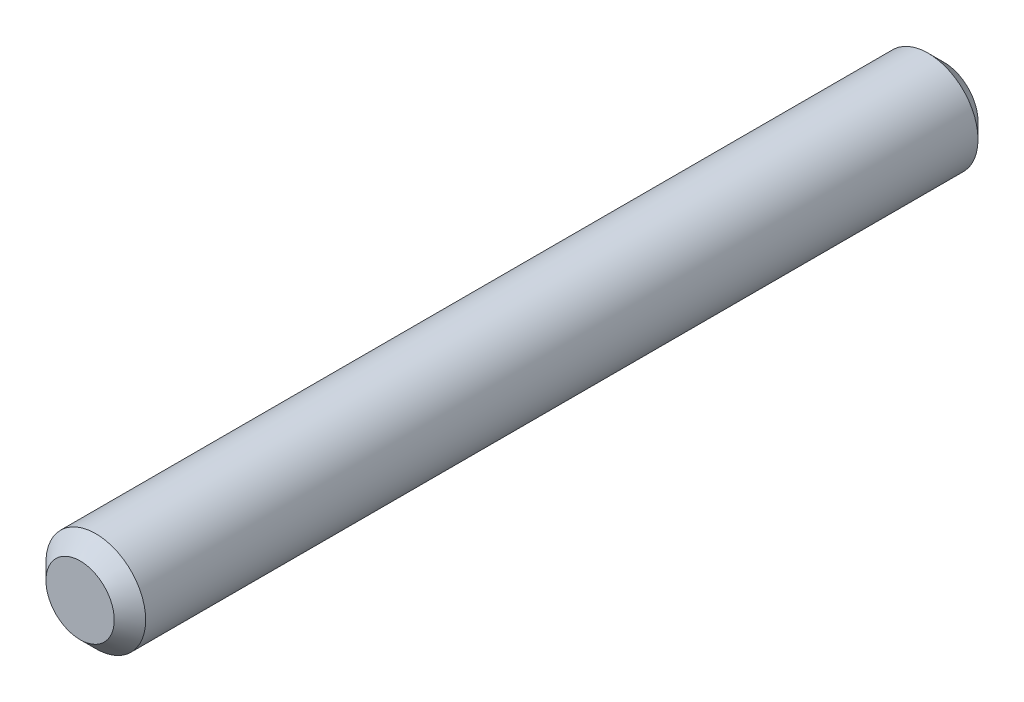
from build123d import *

# Parameters (mm, degrees)
SKETCH1_R           = 3.175
BOSS_EXTRUDE1_DEPTH = 55
CHAMFER1_SIZE       = 1


with BuildPart() as part:
    # Sketch1 → Boss-Extrude1 (new body)
    with BuildSketch(Plane.XY):
        Circle(SKETCH1_R)
    extrude(amount=-BOSS_EXTRUDE1_DEPTH)

    # Chamfer1
    chamfer1_edges = [part.edges().sort_by_distance(p)[0] for p in [
        (-3.175, 0, 0),
        (-3.175, 0, -55),
    ]]
    chamfer(chamfer1_edges, length=CHAMFER1_SIZE)


solid = part.part
